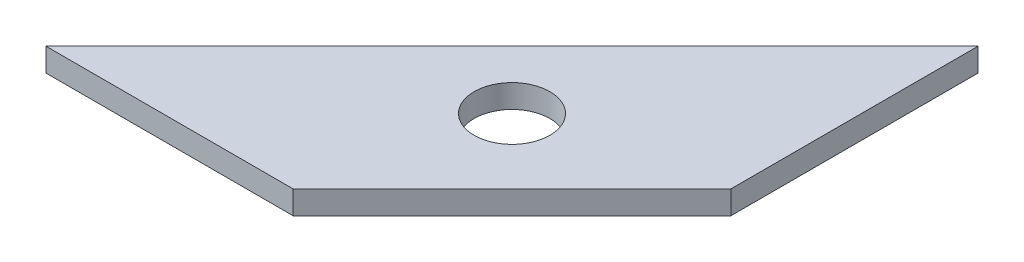
from build123d import *

# Parameters (mm, degrees)
EXTRUDE1_DEPTH                 = 2
F_6_5_6_5_DIAMETER_HOLE1_D     = 6.5
F_6_5_6_5_DIAMETER_HOLE1_DEPTH = 2


with BuildPart() as part:
    # Sketch1 → Extrude1 (new body)
    with BuildSketch(Plane(origin=(0, 0, 0), x_dir=(1, 0, 0), z_dir=(0, 1, 0))):
        Polygon((-40, 0), (-18.786796564, 0), (0, 18.786796564), (0, 40), align=None)
    extrude(amount=EXTRUDE1_DEPTH)

    # Ø6.5 (6.5) Diameter Hole1
    with Locations(Plane(origin=(0, 2, 0), x_dir=(1, 0, 0), z_dir=(0, 1, 0))):
        with Locations((-15, 15)):
            Hole(F_6_5_6_5_DIAMETER_HOLE1_D / 2, depth=F_6_5_6_5_DIAMETER_HOLE1_DEPTH)


solid = part.part
